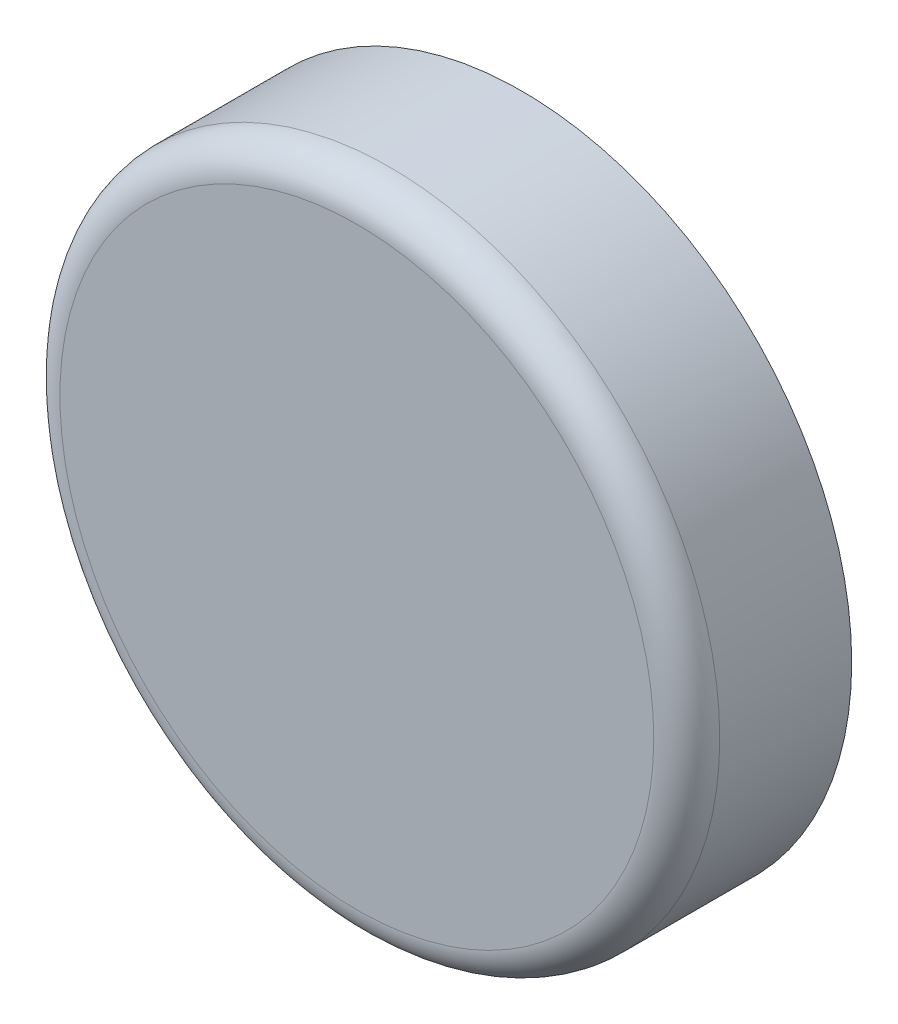
from build123d import *

# Parameters (mm, degrees)
SKETCH1_R           = 10
BOSS_EXTRUDE1_DEPTH = 5
FILLET1_R           = 1


with BuildPart() as part:
    # Sketch1 → Boss-Extrude1 (new body)
    with BuildSketch(Plane.XY):
        with Locations((-11.227748771, 10.677211269)):
            Circle(SKETCH1_R)
    extrude(amount=BOSS_EXTRUDE1_DEPTH)

    # Fillet1
    fillet1_edges = [part.edges().sort_by_distance(p)[0] for p in [
        (-21.227748771, 10.677211269, 5),
    ]]
    fillet(fillet1_edges, radius=FILLET1_R)


solid = part.part
